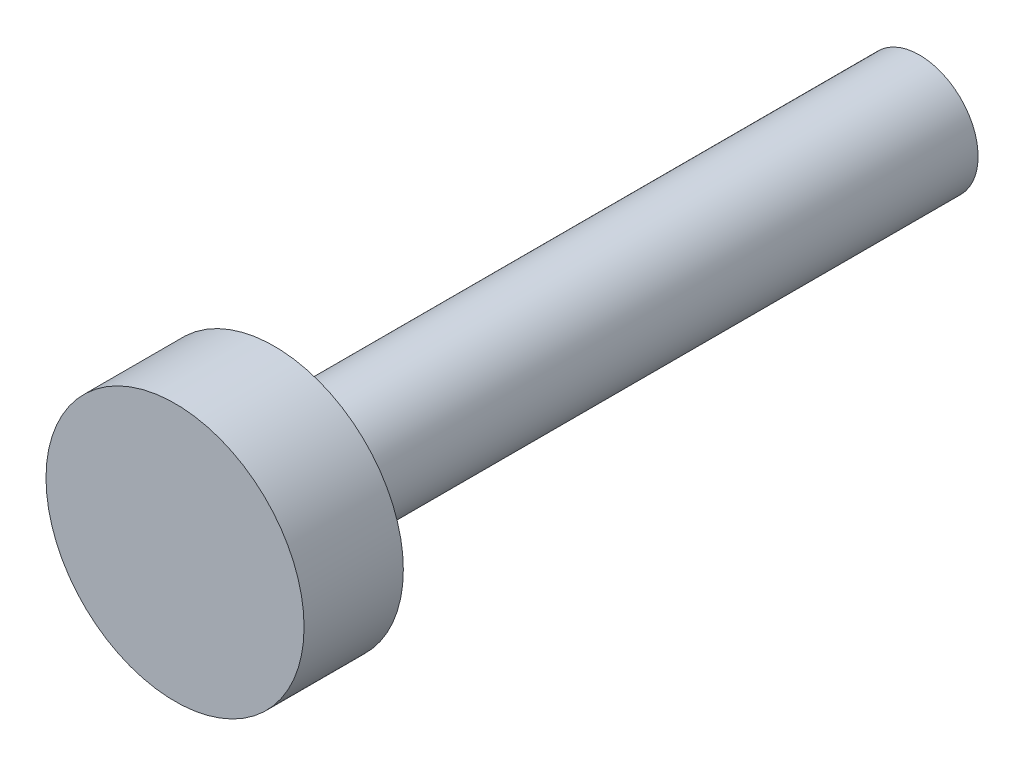
from build123d import *

# Parameters (mm, degrees)
SKETCH1_R         = 3.302
EXTRUDE1_DEPTH    = 19.05
SKETCH2_OUTSIDE_W = 12.848
SKETCH2_OUTSIDE_H = 12.848
SKETCH2_OUTSIDE_R = 1.5
EXTRUDE2_DEPTH    = 16.51


with BuildPart() as part:
    # Sketch1 → Extrude1 (new body)
    with BuildSketch(Plane.XY):
        Circle(SKETCH1_R)
    extrude(amount=EXTRUDE1_DEPTH)

    # Sketch2 outside → Extrude2 (cut)
    with BuildSketch(Plane(origin=(0, 0, 0), x_dir=(-1, 0, 0), z_dir=(0, 0, -1))):
        Rectangle(SKETCH2_OUTSIDE_W, SKETCH2_OUTSIDE_H)
        Circle(SKETCH2_OUTSIDE_R, mode=Mode.SUBTRACT)
    extrude(amount=-EXTRUDE2_DEPTH, mode=Mode.SUBTRACT)


solid = part.part
